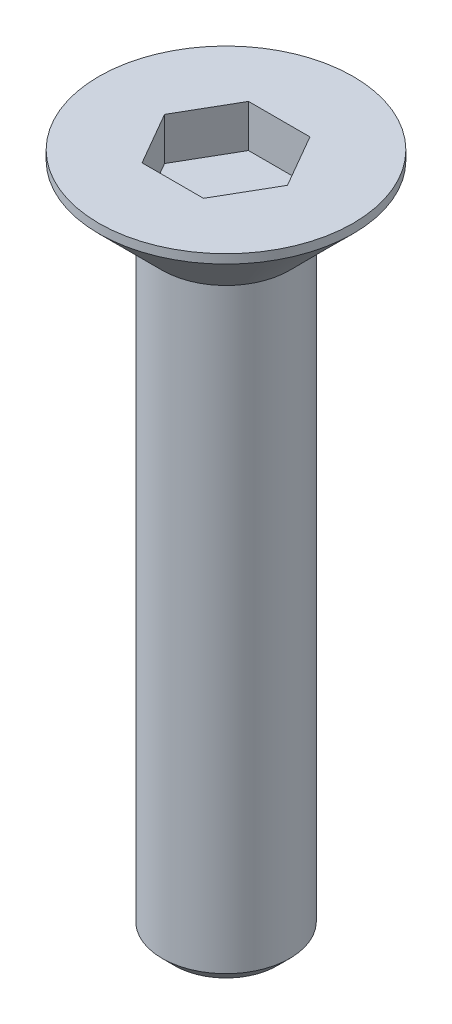
from build123d import *

# Parameters (mm, degrees)
CHAFL_N2_SIZE         = 0.3
CHAFL_N2_SIZE2        = 0.212132034
CHAFL_N3_SIZE         = 0.3
CORTAR_EXTRUIR2_DEPTH = 1


with BuildPart() as part:
    # Croquis1 → Revolución1 (revolve)
    with BuildSketch(Plane.XY, mode=Mode.PRIVATE) as revoluci_n1_sk:
        Polygon((0, 0), (3.2, 0), (1.5, -1.7), (1.5, -16), (0, -16), align=None)
    revolve(revoluci_n1_sk.sketch.rotate(Axis((0, 0, 0), (0, -1, 0)), 90), axis=Axis((0, 0, 0), (0, -1, 0)))

    # Chaflán2
    chafl_n2_edges = [part.edges().sort_by_distance(p)[0] for p in [
        (0, 0, -3.2),
    ]]
    chafl_n2_side = [part.faces().sort_by_distance(p)[0] for p in [
        (0, -0.85, -2.35),
    ]]
    chamfer(chafl_n2_edges, length=CHAFL_N2_SIZE, length2=CHAFL_N2_SIZE2, reference=chafl_n2_side[0])

    # Chaflán3
    chafl_n3_edges = [part.edges().sort_by_distance(p)[0] for p in [
        (0, -16, -1.5),
    ]]
    chamfer(chafl_n3_edges, length=CHAFL_N3_SIZE)

    # Croquis3 → Cortar-Extruir2 (cut)
    with BuildSketch(Plane(origin=(0, 0, 0), x_dir=(1, 0, 0), z_dir=(0, 1, 0))):
        Polygon((-0.721687836, 1.25), (-1.443375673, 0), (-0.721687836, -1.25), (0.721687836, -1.25), (1.443375673, 0), (0.721687836, 1.25), align=None)
    extrude(amount=-CORTAR_EXTRUIR2_DEPTH, mode=Mode.SUBTRACT)


solid = part.part
